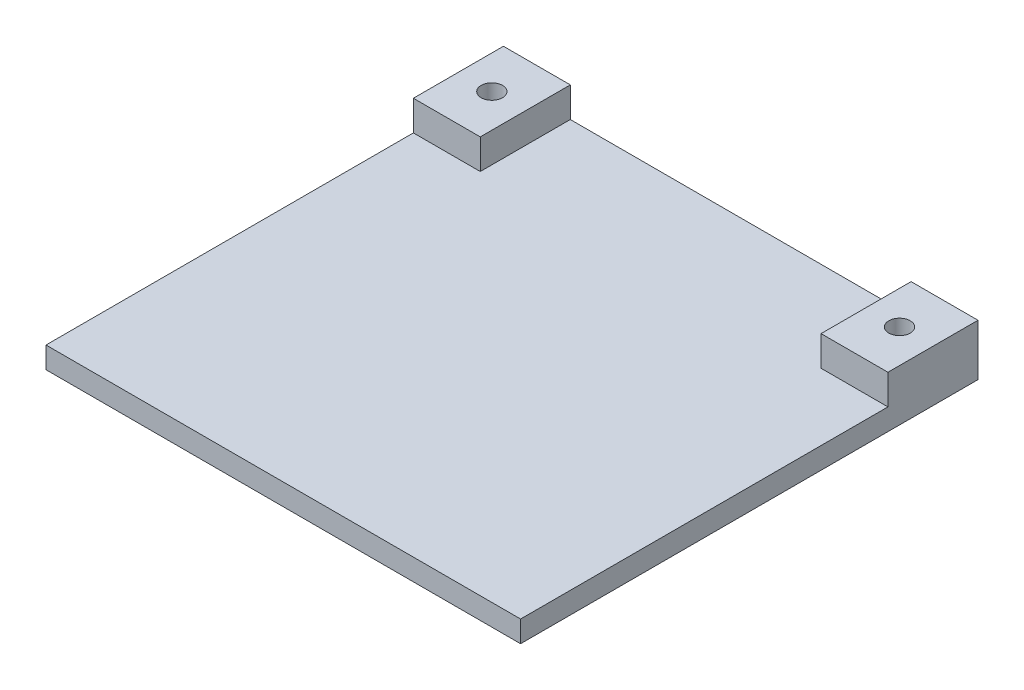
from build123d import *

# Parameters (mm, degrees)
BOSS_EXTRUDE1_DEPTH      = 1.27
BOSS_EXTRUDE1_DEPTH_BACK = 0.635
SKETCH1_W                = 42.164
SKETCH1_H                = 40.64
SKETCH1_R                = 0.9525
SKETCH1_4_W              = 5.9436
SKETCH1_4_H              = 8.001
SKETCH1_4_R              = 0.9525
BOSS_EXTRUDE2_DEPTH      = 3.937


with BuildPart() as part:
    # Sketch1 → Boss-Extrude1 (new, two sides: drawn at the far end of the back side and taken through both)
    with BuildSketch(Plane(origin=(0, 0, 0), x_dir=(1, 0, 0), z_dir=(0, 1, 0)).offset(-BOSS_EXTRUDE1_DEPTH_BACK)):
        Rectangle(SKETCH1_W, SKETCH1_H)
        with Locations((18.1102, 16.3195)):
            Circle(SKETCH1_R, mode=Mode.SUBTRACT)
        with Locations((-18.1102, 16.3195)):
            Circle(SKETCH1_R, mode=Mode.SUBTRACT)
    extrude(amount=BOSS_EXTRUDE1_DEPTH + BOSS_EXTRUDE1_DEPTH_BACK)

    # Sketch1_4 → Boss-Extrude2 (add)
    # profile 1 of 2: a face of its own
    with BuildSketch(Plane(origin=(0, 0, 0), x_dir=(1, 0, 0), z_dir=(0, 1, 0))):
        with Locations((18.1102, 16.3195)):
            Rectangle(SKETCH1_4_W, SKETCH1_4_H)
        with Locations((18.1102, 16.3195)):
            Circle(SKETCH1_4_R, mode=Mode.SUBTRACT)
    # profile 2 of 2: a face of its own
    with BuildSketch(Plane(origin=(0, 0, 0), x_dir=(1, 0, 0), z_dir=(0, 1, 0))):
        with Locations((-18.1102, 16.3195)):
            Rectangle(SKETCH1_4_W, SKETCH1_4_H)
        with Locations((-18.1102, 16.3195)):
            Circle(SKETCH1_4_R, mode=Mode.SUBTRACT)
    extrude(amount=BOSS_EXTRUDE2_DEPTH)


solid = part.part
